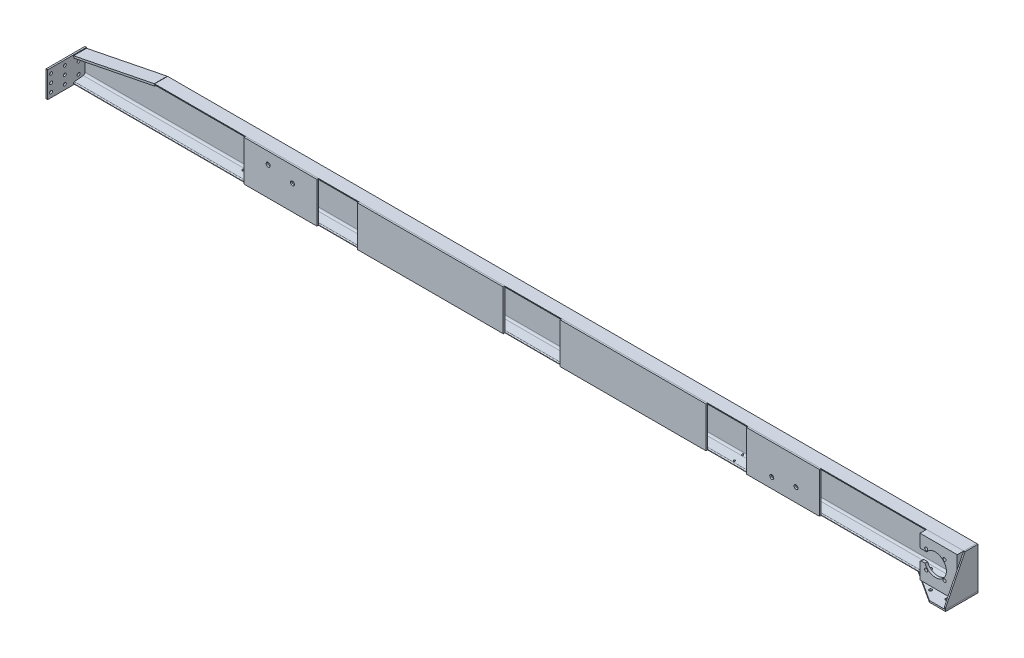
from build123d import *

# Parameters (mm, degrees)
MEMBER_25B_1_DEPTH       = 5490
CUT_EXTRUDE_1_REACH      = 2759.522
EXTRUDE_1_DEPTH          = 80
SKETCH_14_W              = 240
SKETCH_14_H              = 160
EXTRUDE_2_DEPTH          = 10
SKETCH_15_W              = 450
SKETCH_15_H              = 250
EXTRUDE_3_DEPTH          = 10
SKETCH_15_W_2            = 900
EXTRUDE_3_2_DEPTH        = 10
EXTRUDE_3_3_DEPTH        = 10
EXTRUDE_3_4_DEPTH        = 10
EXTRUDE_4_DEPTH          = 10
EXTRUDE_5_DEPTH          = 8
CUT_EXTRUDE_START        = -90
SKETCH_18_R              = 12.5
CUT_EXTRUDE_2_DEPTH      = 90
SKETCH_19_R              = 12.5
CUT_EXTRUDE_3_DEPTH      = 90
SKETCH_20_W              = 50
SKETCH_20_H              = 71
CUT_EXTRUDE_4_DEPTH      = 26.40959
SKETCH_21_W              = 180
SKETCH_21_H              = 71
CUT_EXTRUDE_5_DEPTH      = 26.40959
SKETCH_22_R              = 9
CUT_EXTRUDE_6_DEPTH      = 10
SKETCH_23_W              = 230
SKETCH_23_H              = 250
SKETCH_23_R              = 68
SKETCH_23_R_2            = 9.5
EXTRUDE_6_DEPTH          = 40
CUT_EXTRUDE_7_REACH      = 5283.382
CUT_EXTRUDE_7_END_RADIUS = 68
SKETCH_24_W              = 40
SKETCH_24_H              = 65
SKETCH_25_W              = 24
SKETCH_25_H              = 230
CUT_EXTRUDE_8_DEPTH      = 220
FILLET_1_R               = 20
FILLET_2_R               = 10
SKETCH_26_R              = 9
CUT_EXTRUDE_9_DEPTH      = 10
CUT_EXTRUDE_11_REACH     = 2778.711
SKETCH_26_2_R            = 9
CUT_EXTRUDE_12_REACH     = 2778.711
SKETCH_27_R              = 7
PATTERN_LINEAR_1_COUNT   = 2
PATTERN_LINEAR_1_PITCH   = 3460
FILLET_3_R               = 5
SKETCH_115_R             = 5
CUT_EXTRUDE_13_DEPTH     = 105.5


with BuildPart() as part:
    # 草图114 → Member 25B_1 (new body)
    with BuildSketch(Plane(origin=(-2745, 125, 0), x_dir=(0, 0, 1), z_dir=(1, 0, 0))):
        with BuildLine():
            Line((0, -125), (80, -125))
            Line((80, -125), (80, -121.979610687))
            ThreePointArc((80, -121.979610687), (78.448694362, -117.953555736), (74.596960509, -116.009381366))
            Line((74.596960509, -116.009381366), (19.806078982, -110.530866091))
            ThreePointArc((19.806078982, -110.530866091), (12.102611276, -106.642517351), (9, -98.590407448))
            Line((9, -98.590407448), (9, 98.590407448))
            ThreePointArc((9, 98.590407448), (12.102611276, 106.642517351), (19.806078982, 110.530866091))
            Line((19.806078982, 110.530866091), (74.596960509, 116.009381366))
            ThreePointArc((74.596960509, 116.009381366), (78.448694362, 117.953555736), (80, 121.979610687))
            Line((80, 121.979610687), (80, 125))
            Line((80, 125), (0, 125))
            Line((0, 125), (0, -125))
        make_face()
    extrude(amount=MEMBER_25B_1_DEPTH)

    # 草图12 → 切除-拉伸1 (cut, up to next)
    with BuildSketch(Plane(origin=(0, 0, 0), x_dir=(-1, 0, 0), z_dir=(0, 0, -1)), mode=Mode.PRIVATE) as cut_extrude_1_sk1:
        Polygon((2745, 250), (2745, 137.762353167), (2245, 237.762353167), (2245, 250), align=None)
    cut_extrude_1_tool1 = extrude(cut_extrude_1_sk1.sketch, amount=-CUT_EXTRUDE_1_REACH, mode=Mode.PRIVATE) & part.part
    add(cut_extrude_1_tool1.solids().sort_by_distance((-2561.94769, 212.186408, 0))[0], mode=Mode.SUBTRACT)


with BuildPart() as body_2:
    # 草图13 → 凸台-拉伸1 (new body)
    with BuildSketch(Plane(origin=(0, 0, 0), x_dir=(-1, 0, 0), z_dir=(0, 0, -1))):
        Polygon((2245, 237.762353167), (2742.646606378, 138.233031892), (2745, 150), (2247.353393622, 249.529321276), align=None)
    extrude(amount=-EXTRUDE_1_DEPTH)


with BuildPart() as body_3:
    # 草图14 → 凸台-拉伸2 (new body)
    with BuildSketch(Plane.ZY.offset(2745)):
        with Locations((120, 75)):
            Rectangle(SKETCH_14_W, SKETCH_14_H)
    extrude(amount=EXTRUDE_2_DEPTH)

    # 草图22 → 切除-拉伸6 (cut)
    with BuildSketch(Plane.ZY.offset(2755)):
        with Locations((134, 25)):
            Circle(SKETCH_22_R)
        with Locations((219, 25)):
            Circle(SKETCH_22_R)
        with Locations((219, 75)):
            Circle(SKETCH_22_R)
        with Locations((219, 125)):
            Circle(SKETCH_22_R)
        with Locations((134, 75)):
            Circle(SKETCH_22_R)
        with Locations((49, 105)):
            Circle(SKETCH_22_R)
        with Locations((49, 35)):
            Circle(SKETCH_22_R)
        with Locations((134, 125)):
            Circle(SKETCH_22_R)
    extrude(amount=-CUT_EXTRUDE_6_DEPTH, mode=Mode.SUBTRACT)


with BuildPart() as body_4:
    # 草图15 → 凸台-拉伸3 (new body)
    with BuildSketch(Plane.XY.offset(80)):
        with Locations((-1460, 125)):
            Rectangle(SKETCH_15_W, SKETCH_15_H)
    extrude(amount=EXTRUDE_3_DEPTH)


with BuildPart() as body_5:
    # 草图15 → Extrude 3 2 (new body)
    with BuildSketch(Plane.XY.offset(80)):
        with Locations((-535, 125)):
            Rectangle(SKETCH_15_W_2, SKETCH_15_H)
    extrude(amount=EXTRUDE_3_2_DEPTH)


with BuildPart() as body_6:
    # 草图15 → Extrude 3 3 (new body)
    with BuildSketch(Plane.XY.offset(80)):
        with Locations((715, 125)):
            Rectangle(SKETCH_15_W_2, SKETCH_15_H)
    extrude(amount=EXTRUDE_3_3_DEPTH)


with BuildPart() as body_7:
    # 草图15 → Extrude 3 4 (new body)
    with BuildSketch(Plane.XY.offset(80)):
        with Locations((1640, 125)):
            Rectangle(SKETCH_15_W, SKETCH_15_H)
    extrude(amount=EXTRUDE_3_4_DEPTH)


with BuildPart() as body_8:
    # 草图16 → 凸台-拉伸4 (new body)
    with BuildSketch(Plane.XZ):
        Polygon((2753, 0), (2453, 0), (2453, 70), (2653, 200), (2753, 200), align=None)
    extrude(amount=EXTRUDE_4_DEPTH)

    # 草图26 → 切除-拉伸9 (cut)
    with BuildSketch(Plane(origin=(0, 0, 0), x_dir=(1, 0, 0), z_dir=(0, 1, 0))):
        with Locations(Location((2601, -140, 0), (0, 0, 270))):
            Circle(SKETCH_26_R)
        with Locations(Location((2701, -140, 0), (0, 0, 270))):
            Circle(SKETCH_26_R)
        with Locations(Location((2701, -40, 0), (0, 0, 270))):
            Circle(SKETCH_26_R)
        with Locations(Location((2601, -40, 0), (0, 0, 270))):
            Circle(SKETCH_26_R)
        with Locations(Location((2501, -40, 0), (0, 0, 270))):
            Circle(SKETCH_26_R)
    extrude(amount=-CUT_EXTRUDE_9_DEPTH, mode=Mode.SUBTRACT)


with BuildPart() as body_9:
    # 草图17 → 凸台-拉伸5 (new body)
    with BuildSketch(Plane(origin=(2745, 0, 0), x_dir=(0, 0, -1), z_dir=(1, 0, 0))):
        Polygon((-80, 250), (0, 250), (0, 0), (-200, 0), (-200, 10), align=None)
    extrude(amount=EXTRUDE_5_DEPTH)


with BuildPart() as cut_extrude_2_tool:
    # 草图18 → 切除-拉伸2 (new body)
    with BuildSketch(Plane.XY.offset(90).offset(CUT_EXTRUDE_START)):
        with Locations((-1535, 178)):
            Circle(SKETCH_18_R)
        with Locations((-1385, 153)):
            Circle(SKETCH_18_R)
    extrude(amount=CUT_EXTRUDE_2_DEPTH)


with BuildPart() as part_1:
    add(part.part)

    # 切除-拉伸2: cut by cut_extrude_2_tool
    add(cut_extrude_2_tool.part, mode=Mode.SUBTRACT)


with BuildPart() as body_4_1:
    add(body_4.part)

    # 切除-拉伸2: cut by cut_extrude_2_tool
    add(cut_extrude_2_tool.part, mode=Mode.SUBTRACT)


with BuildPart() as cut_extrude_3_tool:
    # 草图19 → 切除-拉伸3 (new body)
    with BuildSketch(Plane.XY.offset(90).offset(CUT_EXTRUDE_START)):
        with Locations((1571, 63)):
            Circle(SKETCH_19_R)
        with Locations((1721, 84)):
            Circle(SKETCH_19_R)
    extrude(amount=CUT_EXTRUDE_3_DEPTH)


with BuildPart() as part_2:
    add(part_1.part)

    # 切除-拉伸3: cut by cut_extrude_3_tool
    add(cut_extrude_3_tool.part, mode=Mode.SUBTRACT)

    # 草图20 → 切除-拉伸4 (cut)
    with BuildSketch(Plane.XZ):
        with Locations((-1587, 44.5)):
            Rectangle(SKETCH_20_W, SKETCH_20_H)
    extrude(amount=-CUT_EXTRUDE_4_DEPTH, mode=Mode.SUBTRACT)

    # 草图21 → 切除-拉伸5 (cut)
    with BuildSketch(Plane.XZ):
        with Locations((1606, 44.5)):
            Rectangle(SKETCH_21_W, SKETCH_21_H)
    extrude(amount=-CUT_EXTRUDE_5_DEPTH, mode=Mode.SUBTRACT)

    # 切除-拉伸11: up to this plane
    cut_extrude_11_end = Plane(origin=(2745, 14.469133909, 19.806078982), z_dir=(0, -0.9950382202392988, -0.0994934181893896))
    # 草图26<2> → 切除-拉伸11 (cut, up to the surface)
    with BuildSketch(Plane(origin=(0, 0, 0), x_dir=(1, 0, 0), z_dir=(0, 1, 0)), mode=Mode.PRIVATE) as cut_extrude_11_sk1:
        with Locations(Location((2601, -140, 0), (0, 0, 270))):
            Circle(SKETCH_26_2_R)
    cut_extrude_11_tool1 = split(extrude(cut_extrude_11_sk1.sketch, amount=CUT_EXTRUDE_11_REACH, mode=Mode.PRIVATE), bisect_by=cut_extrude_11_end, keep=Keep.BOTH, mode=Mode.PRIVATE)
    add(cut_extrude_11_tool1.solids().sort_by_distance((2601, 0, 140))[0], mode=Mode.SUBTRACT)
    # 草图26<2> → 切除-拉伸11 (cut, up to the surface)
    with BuildSketch(Plane(origin=(0, 0, 0), x_dir=(1, 0, 0), z_dir=(0, 1, 0)), mode=Mode.PRIVATE) as cut_extrude_11_sk2:
        with Locations(Location((2701, -140, 0), (0, 0, 270))):
            Circle(SKETCH_26_2_R)
    cut_extrude_11_tool2 = split(extrude(cut_extrude_11_sk2.sketch, amount=CUT_EXTRUDE_11_REACH, mode=Mode.PRIVATE), bisect_by=cut_extrude_11_end, keep=Keep.BOTH, mode=Mode.PRIVATE)
    add(cut_extrude_11_tool2.solids().sort_by_distance((2701, 0, 140))[0], mode=Mode.SUBTRACT)
    # 草图26<2> → 切除-拉伸11 (cut, up to the surface)
    with BuildSketch(Plane(origin=(0, 0, 0), x_dir=(1, 0, 0), z_dir=(0, 1, 0)), mode=Mode.PRIVATE) as cut_extrude_11_sk3:
        with Locations(Location((2701, -40, 0), (0, 0, 270))):
            Circle(SKETCH_26_2_R)
    cut_extrude_11_tool3 = split(extrude(cut_extrude_11_sk3.sketch, amount=CUT_EXTRUDE_11_REACH, mode=Mode.PRIVATE), bisect_by=cut_extrude_11_end, keep=Keep.BOTH, mode=Mode.PRIVATE)
    add(cut_extrude_11_tool3.solids().sort_by_distance((2701, 0, 40))[0], mode=Mode.SUBTRACT)
    # 草图26<2> → 切除-拉伸11 (cut, up to the surface)
    with BuildSketch(Plane(origin=(0, 0, 0), x_dir=(1, 0, 0), z_dir=(0, 1, 0)), mode=Mode.PRIVATE) as cut_extrude_11_sk4:
        with Locations(Location((2601, -40, 0), (0, 0, 270))):
            Circle(SKETCH_26_2_R)
    cut_extrude_11_tool4 = split(extrude(cut_extrude_11_sk4.sketch, amount=CUT_EXTRUDE_11_REACH, mode=Mode.PRIVATE), bisect_by=cut_extrude_11_end, keep=Keep.BOTH, mode=Mode.PRIVATE)
    add(cut_extrude_11_tool4.solids().sort_by_distance((2601, 0, 40))[0], mode=Mode.SUBTRACT)
    # 草图26<2> → 切除-拉伸11 (cut, up to the surface)
    with BuildSketch(Plane(origin=(0, 0, 0), x_dir=(1, 0, 0), z_dir=(0, 1, 0)), mode=Mode.PRIVATE) as cut_extrude_11_sk5:
        with Locations(Location((2501, -40, 0), (0, 0, 270))):
            Circle(SKETCH_26_2_R)
    cut_extrude_11_tool5 = split(extrude(cut_extrude_11_sk5.sketch, amount=CUT_EXTRUDE_11_REACH, mode=Mode.PRIVATE), bisect_by=cut_extrude_11_end, keep=Keep.BOTH, mode=Mode.PRIVATE)
    add(cut_extrude_11_tool5.solids().sort_by_distance((2501, 0, 40))[0], mode=Mode.SUBTRACT)

    # 切除-拉伸12: up to this plane
    cut_extrude_12_end = Plane(origin=(2745, 14.469133909, 19.806078982), z_dir=(0, -0.9950382202392988, -0.0994934181893896))
    # 草图27 → 切除-拉伸12 (cut, up to the surface)
    with BuildSketch(Plane.XZ, mode=Mode.PRIVATE) as cut_extrude_12_sk1:
        with Locations(Location((1799, 30, 0), (0, 0, 270))):
            Circle(SKETCH_27_R)
    cut_extrude_12_tool1 = split(extrude(cut_extrude_12_sk1.sketch, amount=-CUT_EXTRUDE_12_REACH, mode=Mode.PRIVATE), bisect_by=cut_extrude_12_end, keep=Keep.BOTH, mode=Mode.PRIVATE)
    # 草图27 → 切除-拉伸12 (cut, up to the surface)
    with BuildSketch(Plane.XZ, mode=Mode.PRIVATE) as cut_extrude_12_sk2:
        with Locations(Location((1713, 30, 0), (0, 0, 270))):
            Circle(SKETCH_27_R)
    cut_extrude_12_tool2 = split(extrude(cut_extrude_12_sk2.sketch, amount=-CUT_EXTRUDE_12_REACH, mode=Mode.PRIVATE), bisect_by=cut_extrude_12_end, keep=Keep.BOTH, mode=Mode.PRIVATE)
    cut_extrude_12 = cut_extrude_12_tool1.solids().sort_by_distance((1799, 0, 30))[0] + cut_extrude_12_tool2.solids().sort_by_distance((1713, 0, 30))[0]
    add(cut_extrude_12, mode=Mode.SUBTRACT)

    # 阵列(线性)1: 切除-拉伸12 ×2
    with Locations(*[(-i * PATTERN_LINEAR_1_PITCH, 0, 0) for i in range(1, PATTERN_LINEAR_1_COUNT)]):
        add(cut_extrude_12, mode=Mode.SUBTRACT)

    # 草图115 → 切除-拉伸13 (cut)
    with BuildSketch(Plane.XZ):
        with Locations(Location((1316, 15, 0), (0, 0, 270))):
            Circle(SKETCH_115_R)
        with Locations(Location((1316, 65, 0), (0, 0, 270))):
            Circle(SKETCH_115_R)
        with Locations(Location((1416, 65, 0), (0, 0, 270))):
            Circle(SKETCH_115_R)
        with Locations(Location((1416, 15, 0), (0, 0, 270))):
            Circle(SKETCH_115_R)
    extrude(amount=-CUT_EXTRUDE_13_DEPTH, mode=Mode.SUBTRACT)


with BuildPart() as body_7_1:
    add(body_7.part)

    # 切除-拉伸3: cut by cut_extrude_3_tool
    add(cut_extrude_3_tool.part, mode=Mode.SUBTRACT)


with BuildPart() as body_10:
    # 草图23 → 凸台-拉伸6 (new body)
    with BuildSketch(Plane.XY.offset(80)):
        with Locations((2630, 125)):
            Rectangle(SKETCH_23_W, SKETCH_23_H)
        with Locations((2610, 129)):
            Circle(SKETCH_23_R, mode=Mode.SUBTRACT)
        with Locations((2553.431457505, 185.568542495)):
            Circle(SKETCH_23_R_2, mode=Mode.SUBTRACT)
        with Locations((2666.568542495, 185.568542495)):
            Circle(SKETCH_23_R_2, mode=Mode.SUBTRACT)
        with Locations((2666.568542495, 72.431457505)):
            Circle(SKETCH_23_R_2, mode=Mode.SUBTRACT)
        with Locations((2553.431457505, 72.431457505)):
            Circle(SKETCH_23_R_2, mode=Mode.SUBTRACT)
    extrude(amount=EXTRUDE_6_DEPTH)

    # 切除-拉伸7: up to this cylinder (the profile starts outside it)
    cut_extrude_7_end = Plane(origin=(2610, 129, 100), z_dir=(0, 0, -1)) * Cylinder(CUT_EXTRUDE_7_END_RADIUS, 10703.764, mode=Mode.PRIVATE)
    # 草图24 → 切除-拉伸7 (cut, up to the surface)
    with BuildSketch(Plane.ZY.offset(-2515), mode=Mode.PRIVATE) as cut_extrude_7_sk1:
        with Locations((100, 138)):
            Rectangle(SKETCH_24_W, SKETCH_24_H)
    cut_extrude_7_tool1 = extrude(cut_extrude_7_sk1.sketch, amount=-CUT_EXTRUDE_7_REACH, mode=Mode.PRIVATE) - cut_extrude_7_end
    add(cut_extrude_7_tool1.solids().sort_by_distance((2515, 138, 100))[0], mode=Mode.SUBTRACT)

    # 草图25 → 切除-拉伸8 (cut)
    with BuildSketch(Plane.ZY.offset(-2515)):
        with Locations((92, 125)):
            Rectangle(SKETCH_25_W, SKETCH_25_H)
    extrude(amount=-CUT_EXTRUDE_8_DEPTH, mode=Mode.SUBTRACT)

    # 圆角1
    fillet_1_edges = [body_10.edges().sort_by_distance(p)[0] for p in [
        (2735, 240, 92),
        (2735, 10, 92),
    ]]
    fillet(fillet_1_edges, radius=FILLET_1_R)

    # 圆角2
    fillet_2_edges = [body_10.edges().sort_by_distance(p)[0] for p in [
        (2515, 170.5, 112),
        (2515, 105.5, 112),
    ]]
    fillet(fillet_2_edges, radius=FILLET_2_R)

    # 圆角3
    fillet_3_edges = [body_10.edges().sort_by_distance(p)[0] for p in [
        (2735, 125, 104),
        (2615, 240, 104),
        (2615, 10, 104),
        (2729.142135624, 234.142135624, 104),
        (2729.142135624, 15.857864376, 104),
    ]]
    fillet(fillet_3_edges, radius=FILLET_3_R)


solid = Compound([body_2.part, body_3.part, body_5.part, body_6.part, body_8.part, body_9.part, body_4_1.part, part_2.part, body_7_1.part, body_10.part])
